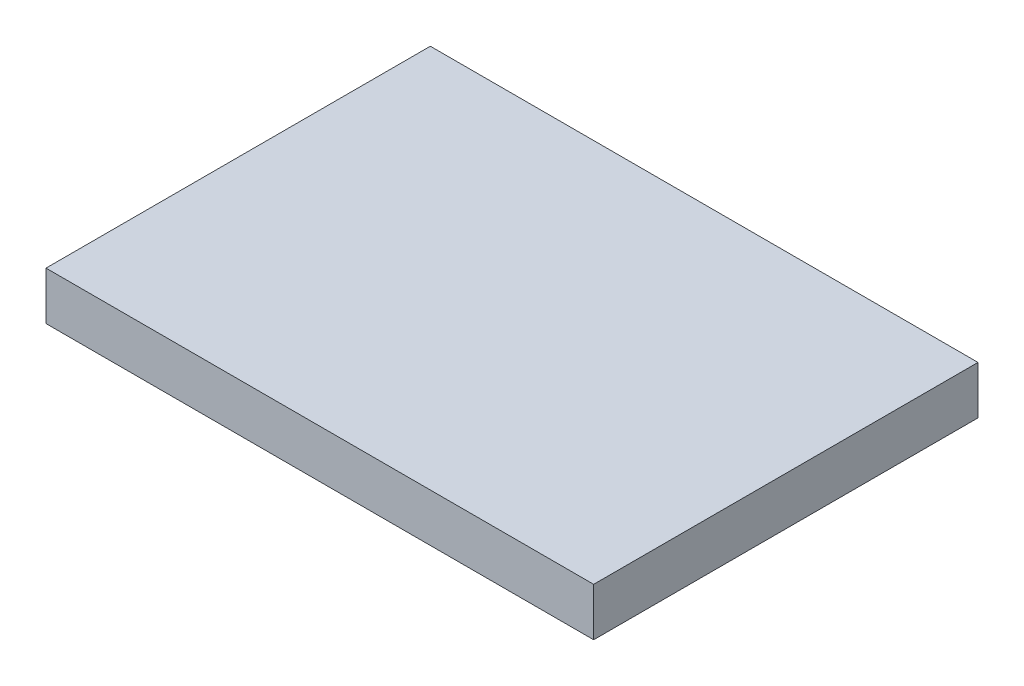
from build123d import *

# Parameters (mm, degrees)
CROQUIS1_W              = 57
CROQUIS1_H              = 40
SALIENTE_EXTRUIR1_DEPTH = 5


with BuildPart() as part:
    # Croquis1 → Saliente-Extruir1 (new body)
    with BuildSketch(Plane(origin=(0, 0, 0), x_dir=(1, 0, 0), z_dir=(0, 1, 0))):
        with Locations((-12.36259542, -7.511450382)):
            Rectangle(CROQUIS1_W, CROQUIS1_H)
    extrude(amount=SALIENTE_EXTRUIR1_DEPTH)


solid = part.part
